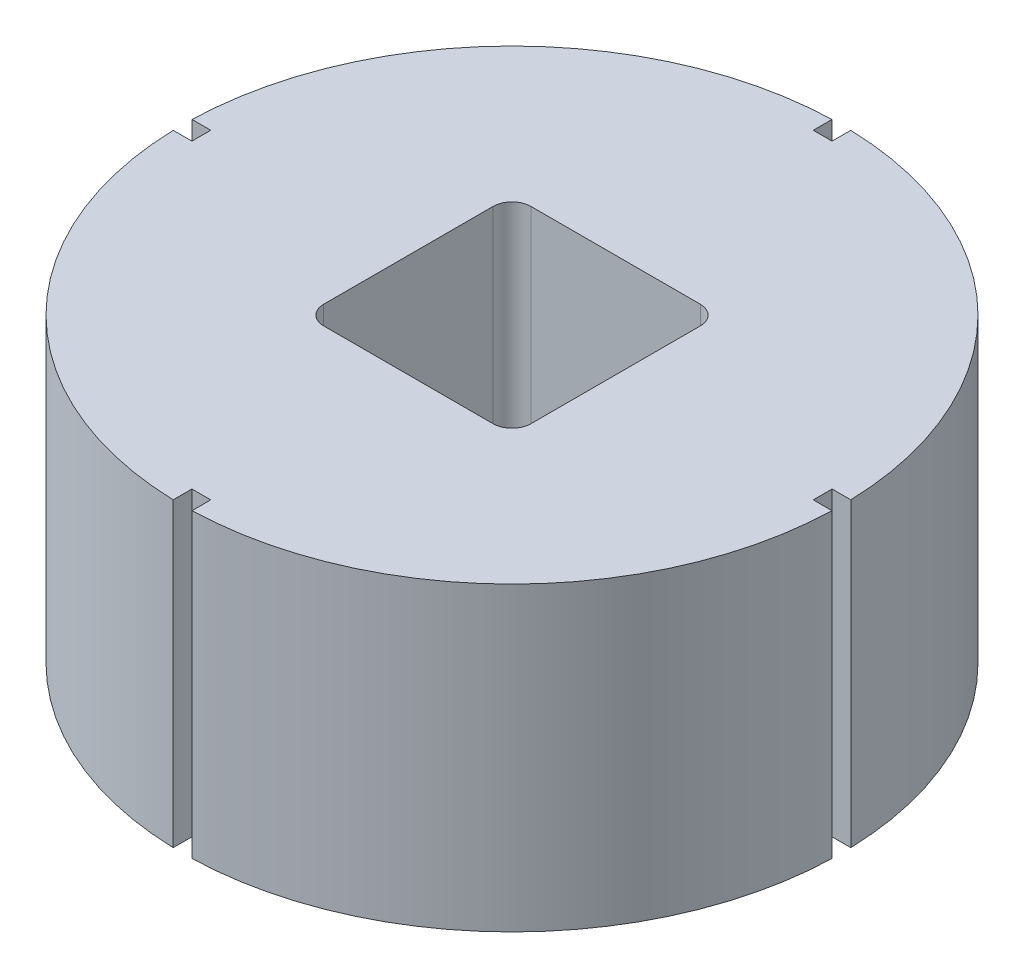
from build123d import *

# Parameters (mm, degrees)
SKETCH1_R           = 35
BOSS_EXTRUDE1_DEPTH = 32
SKETCH2_R           = 10
BOSS_EXTRUDE2_DEPTH = 5
CUT_EXTRUDE1_DEPTH  = 25
CUT_EXTRUDE2_DEPTH  = 36


with BuildPart() as part:
    # Sketch1 → Boss-Extrude1 (new body)
    with BuildSketch(Plane(origin=(0, 0, 0), x_dir=(1, 0, 0), z_dir=(0, 1, 0))):
        Circle(SKETCH1_R)
    extrude(amount=BOSS_EXTRUDE1_DEPTH)

    # Sketch2 → Boss-Extrude2 (add)
    with BuildSketch(Plane.XZ):
        Circle(SKETCH2_R)
    extrude(amount=BOSS_EXTRUDE2_DEPTH)

    # Sketch3 → Cut-Extrude1 (cut)
    with BuildSketch(Plane(origin=(0, 32, 0), x_dir=(1, 0, 0), z_dir=(0, 1, 0))):
        with BuildLine():
            Line((-9, 11), (9, 11))
            ThreePointArc((9, 11), (10.414213562, 10.414213562), (11, 9))
            Line((11, 9), (11, -9))
            ThreePointArc((11, -9), (10.414213562, -10.414213562), (9, -11))
            Line((9, -11), (-9, -11))
            ThreePointArc((-9, -11), (-10.414213562, -10.414213562), (-11, -9))
            Line((-11, -9), (-11, 9))
            ThreePointArc((-11, 9), (-10.414213562, 10.414213562), (-9, 11))
        make_face()
    extrude(amount=-CUT_EXTRUDE1_DEPTH, mode=Mode.SUBTRACT)

    # Sketch4 → Cut-Extrude2 (cut)
    with BuildSketch(Plane(origin=(0, 32, 0), x_dir=(1, 0, 0), z_dir=(0, 1, 0))):
        with BuildLine():
            Line((-1, 34.985711369), (-1, 33))
            Line((-1, 33), (1, 33))
            Line((1, 33), (1, 34.985711369))
            ThreePointArc((1, 34.985711369), (0, 35), (-1, 34.985711369))
        make_face()
        with BuildLine():
            Line((34.985711369, 1), (33, 1))
            Line((33, 1), (33, -1))
            Line((33, -1), (34.985711369, -1))
            ThreePointArc((34.985711369, -1), (35, 0), (34.985711369, 1))
        make_face()
        with BuildLine():
            Line((1, -34.985711369), (1, -33))
            Line((1, -33), (-1, -33))
            Line((-1, -33), (-1, -34.985711369))
            ThreePointArc((-1, -34.985711369), (0, -35), (1, -34.985711369))
        make_face()
        with BuildLine():
            Line((-34.985711369, -1), (-33, -1))
            Line((-33, -1), (-33, 1))
            Line((-33, 1), (-34.985711369, 1))
            ThreePointArc((-34.985711369, 1), (-35, 0), (-34.985711369, -1))
        make_face()
    extrude(amount=-CUT_EXTRUDE2_DEPTH, mode=Mode.SUBTRACT)


solid = part.part
